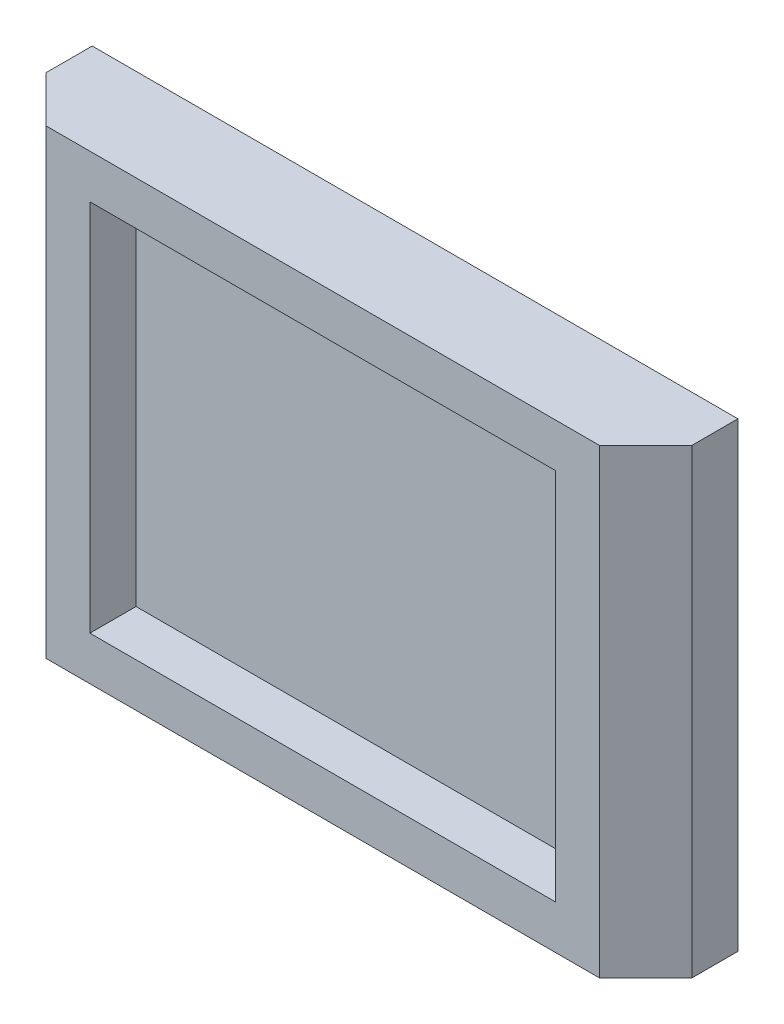
from build123d import *

# Parameters (mm, degrees)
SKIZZE1_W                       = 70
SKIZZE1_H                       = 50
AUFSATZ_LINEAR_AUSTRAGEN1_DEPTH = 10
SKIZZE2_W                       = 50.5
SKIZZE2_H                       = 40.5
SCHNITT_LINEAR_AUSTRAGEN1_DEPTH = 5
FASE2_SIZE                      = 5


with BuildPart() as part:
    # Skizze1 → Aufsatz-Linear austragen1 (new body)
    with BuildSketch(Plane.XY):
        Rectangle(SKIZZE1_W, SKIZZE1_H)
    extrude(amount=AUFSATZ_LINEAR_AUSTRAGEN1_DEPTH)

    # Skizze2 → Schnitt-Linear austragen1 (cut)
    with BuildSketch(Plane.XY.offset(10)):
        Rectangle(SKIZZE2_W, SKIZZE2_H)
    extrude(amount=-SCHNITT_LINEAR_AUSTRAGEN1_DEPTH, mode=Mode.SUBTRACT)

    # Fase2
    fase2_edges = [part.edges().sort_by_distance(p)[0] for p in [
        (35, 0, 10),
        (-35, 0, 10),
    ]]
    chamfer(fase2_edges, length=FASE2_SIZE)


solid = part.part
